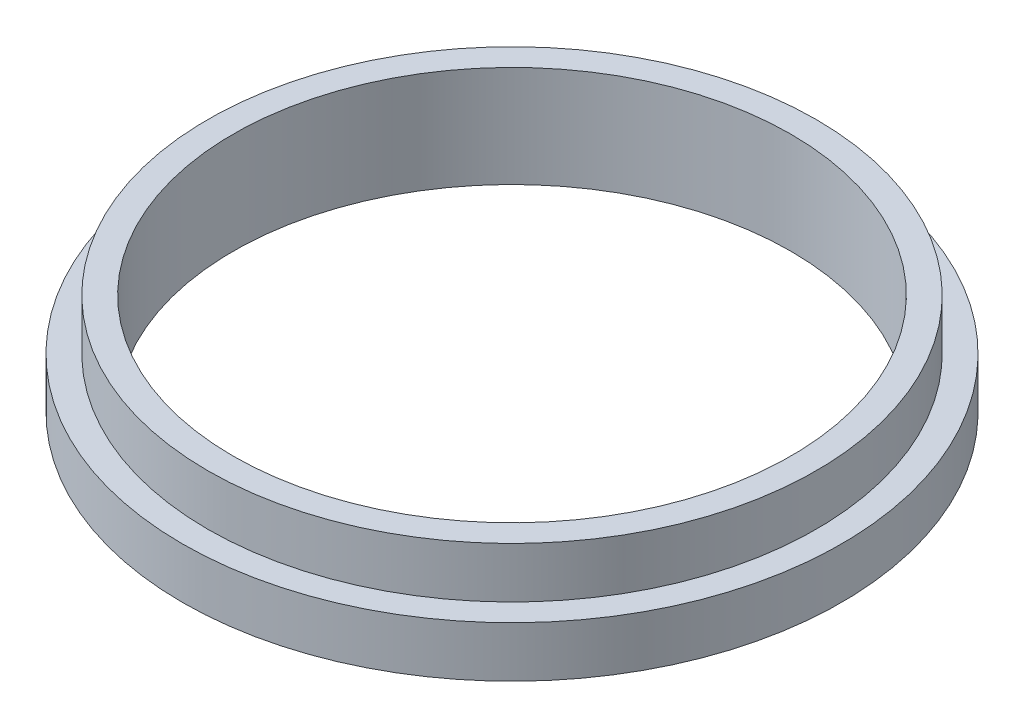
from build123d import *

# Parameters (mm, degrees)
CROQUIS2_R              = 65
CROQUIS2_R_2            = 55
SALIENTE_EXTRUIR1_DEPTH = 10
CROQUIS3_R              = 60
CROQUIS3_R_2            = 55
SALIENTE_EXTRUIR2_DEPTH = 10


with BuildPart() as part:
    # Croquis2 → Saliente-Extruir1 (new body)
    with BuildSketch(Plane(origin=(0, 0, 0), x_dir=(1, 0, 0), z_dir=(0, 1, 0))):
        Circle(CROQUIS2_R)
        Circle(CROQUIS2_R_2, mode=Mode.SUBTRACT)
    extrude(amount=SALIENTE_EXTRUIR1_DEPTH)

    # Croquis3 → Saliente-Extruir2 (add)
    with BuildSketch(Plane(origin=(0, 10, 0), x_dir=(1, 0, 0), z_dir=(0, 1, 0))):
        Circle(CROQUIS3_R)
        Circle(CROQUIS3_R_2, mode=Mode.SUBTRACT)
    extrude(amount=SALIENTE_EXTRUIR2_DEPTH)


solid = part.part
